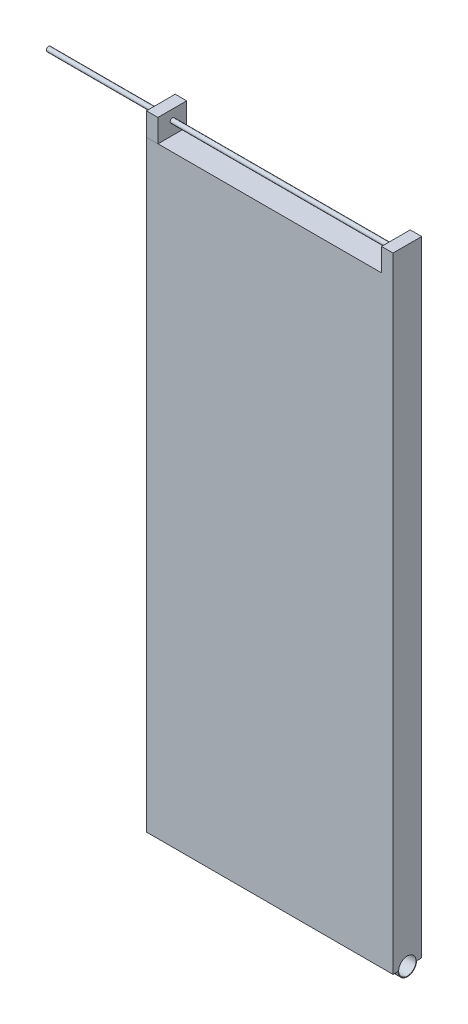
from build123d import *

# Parameters (mm, degrees)
ESQUISSE1_W             = 12.5
ESQUISSE1_H             = 262.5
BOSS_EXTRU_1_DEPTH      = 107.5
ESQUISSE5_R             = 4
BOSS_EXTRU_2_DEPTH      = 107.5
ESQUISSE6_R             = 3.8
ENL_V_MAT_EXTRU_1_DEPTH = 108.5
ESQUISSE8_W             = 5
ESQUISSE8_H             = 12.552801664
BOSS_EXTRU_3_DEPTH      = 10
ESQUISSE9_W             = 5
ESQUISSE9_H             = 12.5
BOSS_EXTRU_4_DEPTH      = 10
BOSS_EXTRU_5_DEPTH      = 101
BOSS_EXTRU_5_DEPTH_BACK = 54
ESQUISSE12_R            = 1


with BuildPart() as part:
    # Esquisse1 → Boss.-Extru.1 (new body)
    with BuildSketch(Plane(origin=(0, 0, 0), x_dir=(0, 0, -1), z_dir=(1, 0, 0))):
        Rectangle(ESQUISSE1_W, ESQUISSE1_H)
    extrude(amount=BOSS_EXTRU_1_DEPTH)

    # Esquisse5 → Boss.-Extru.2 (add)
    with BuildSketch(Plane(origin=(107.5, 0, 0), x_dir=(0, 0, -1), z_dir=(1, 0, 0))):
        with Locations((0, -131.25)):
            Circle(ESQUISSE5_R)
    extrude(amount=-BOSS_EXTRU_2_DEPTH)

    # Esquisse6 → Enlèv. mat.-Extru.1 (cut)
    with BuildSketch(Plane(origin=(107.5, 0, 0), x_dir=(0, 0, -1), z_dir=(1, 0, 0))):
        with Locations((0, -131.179209748)):
            Circle(ESQUISSE6_R)
    extrude(amount=-ENL_V_MAT_EXTRU_1_DEPTH, mode=Mode.SUBTRACT)

    # Esquisse8 → Boss.-Extru.3 (add)
    with BuildSketch(Plane(origin=(0, 131.25, 0), x_dir=(1, 0, 0), z_dir=(0, 1, 0))):
        with Locations((2.5, -0.026400832)):
            Rectangle(ESQUISSE8_W, ESQUISSE8_H)
    extrude(amount=BOSS_EXTRU_3_DEPTH)

    # Esquisse9 → Boss.-Extru.4 (add)
    with BuildSketch(Plane(origin=(0, 131.25, 0), x_dir=(1, 0, 0), z_dir=(0, 1, 0))):
        with Locations((105, 0)):
            Rectangle(ESQUISSE9_W, ESQUISSE9_H)
    extrude(amount=BOSS_EXTRU_4_DEPTH)

    # Esquisse12 → Boss.-Extru.5 (add, two sides: drawn at the far end of the back side and taken through both)
    with BuildSketch(Plane(origin=(5, 0, 0), x_dir=(0, 0, -1), z_dir=(1, 0, 0)).offset(-BOSS_EXTRU_5_DEPTH_BACK)):
        with Locations((0.03, 136.944722229)):
            Circle(ESQUISSE12_R)
    extrude(amount=BOSS_EXTRU_5_DEPTH + BOSS_EXTRU_5_DEPTH_BACK)


solid = part.part
